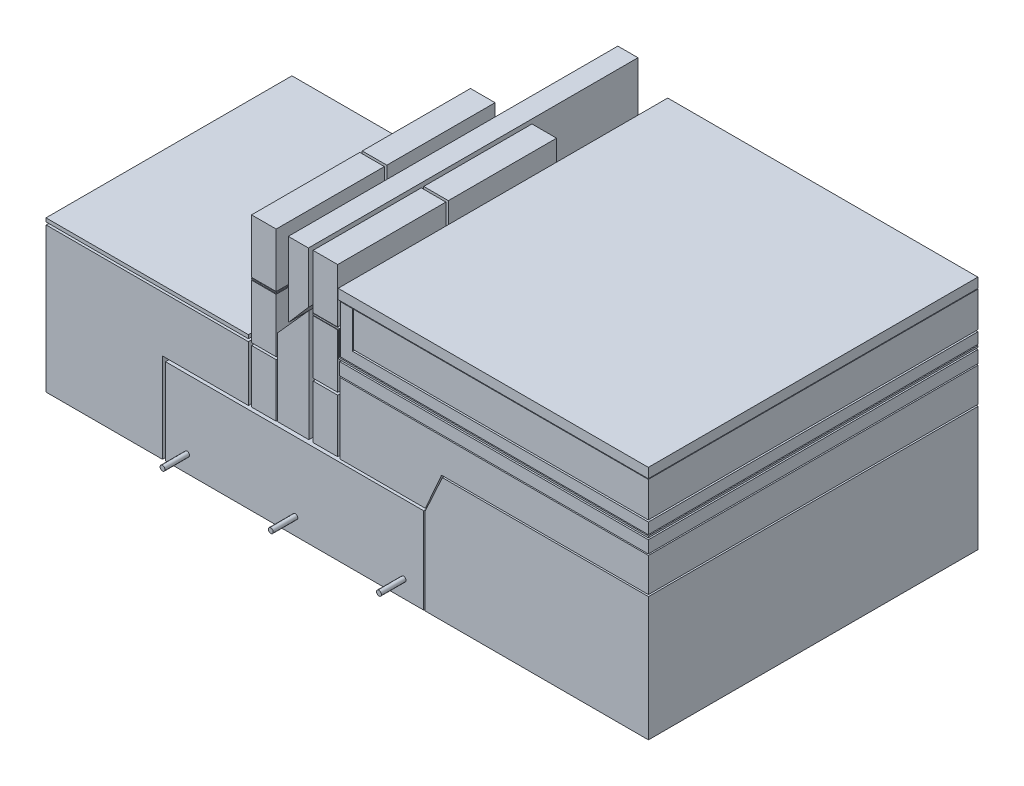
from build123d import *

# Parameters (mm, degrees)
SKETCH1_W        = 1050
SKETCH1_H        = 350
EXTRUDE1_DEPTH   = 1500
SKETCH2_W        = 100
SKETCH2_H        = 216.893893569
EXTRUDE2_DEPTH   = 440
EXTRUDE2_2_DEPTH = 440
SKETCH3_W        = 440
SKETCH3_H        = 220
EXTRUDE3_DEPTH   = 100
EXTRUDE3_2_DEPTH = 100
SKETCH4_W        = 440
SKETCH4_H        = 220
EXTRUDE4_DEPTH   = 100
EXTRUDE4_2_DEPTH = 100
SKETCH6_W        = 215
SKETCH6_H        = 220
EXTRUDE6_DEPTH   = 100
SKETCH6_W_2      = 445.705034037
EXTRUDE6_2_DEPTH = 100
SKETCH6_W_3      = 440
EXTRUDE6_3_DEPTH = 100
SKETCH7_W        = 215
SKETCH7_H        = 220
EXTRUDE7_DEPTH   = 100
SKETCH7_W_2      = 445.705034037
EXTRUDE7_2_DEPTH = 100
SKETCH7_W_3      = 440
EXTRUDE7_3_DEPTH = 100
SKETCH8_W        = 440
SKETCH8_H        = 220
EXTRUDE8_DEPTH   = 100
EXTRUDE8_2_DEPTH = 100
SKETCH9_W        = 440
SKETCH9_H        = 220
EXTRUDE9_DEPTH   = 100
EXTRUDE9_2_DEPTH = 100
SKETCH10_R       = 10
EXTRUDE10_DEPTH  = 100
EXTRUDE11_DEPTH  = 1340
EXTRUDE12_DEPTH  = 1340
EXTRUDE13_DEPTH  = 1340
SKETCH15_W       = 1254.62123021
SKETCH15_H       = 49.983581464
EXTRUDE23_DEPTH  = 1340
SKETCH19_W       = 100.016924429
SKETCH19_H       = 4.415976872
EXTRUDE19_DEPTH  = 1120.705034
EXTRUDE20_DEPTH  = 1000
SKETCH21_W       = 823.020838783
SKETCH21_H       = 14.433926192
EXTRUDE21_DEPTH  = 1000
EXTRUDE22_DEPTH  = 1340
EXTRUDE24_DEPTH  = 1340
EXTRUDE25_DEPTH  = 1340
SKETCH25_W       = 1199.126531933
SKETCH25_H       = 142.62133479
EXTRUDE26_DEPTH  = 1340
SKETCH26_W       = 1261.111632154
SKETCH26_H       = 40
EXTRUDE28_DEPTH  = 1340


with BuildPart() as part:
    # Sketch1 → Extrude1 (new body)
    with BuildSketch(Plane.XY):
        with Locations((-525, 175)):
            Rectangle(SKETCH1_W, SKETCH1_H)
    extrude(amount=-EXTRUDE1_DEPTH)

    # Sketch10 → Extrude10 (add)
    with BuildSketch(Plane.XY):
        with Locations((-962.14462561, 68.901890749)):
            Circle(SKETCH10_R)
        with Locations((-522.14462561, 68.901890749)):
            Circle(SKETCH10_R)
        with Locations((-82.14462561, 68.901890749)):
            Circle(SKETCH10_R)
    extrude(amount=EXTRUDE10_DEPTH)


with BuildPart() as body_2:
    # Sketch2 → Extrude2 (new body)
    with BuildSketch(Plane.XY):
        with Locations((-650, 473.646207299)):
            Rectangle(SKETCH2_W, SKETCH2_H)
    extrude(amount=-EXTRUDE2_DEPTH)


with BuildPart() as body_3:
    # Sketch2 → Extrude2 2 (new body)
    with BuildSketch(Plane.XY):
        with Locations((-400, 473.646207299)):
            Rectangle(SKETCH2_W, SKETCH2_H)
    extrude(amount=-EXTRUDE2_2_DEPTH)


with BuildPart() as body_4:
    # Sketch3 → Extrude3 (new body)
    with BuildSketch(Plane.ZY.offset(700)):
        with Locations((-670, 472.093154083)):
            Rectangle(SKETCH3_W, SKETCH3_H)
    extrude(amount=-EXTRUDE3_DEPTH)


with BuildPart() as body_5:
    # Sketch3 → Extrude3 2 (new body)
    with BuildSketch(Plane.ZY.offset(700)):
        with Locations((-1120, 472.093154083)):
            Rectangle(SKETCH3_W, SKETCH3_H)
    extrude(amount=-EXTRUDE3_2_DEPTH)


with BuildPart() as body_6:
    # Sketch4 → Extrude4 (new body)
    with BuildSketch(Plane(origin=(-350, 0, 0), x_dir=(0, 0, -1), z_dir=(1, 0, 0))):
        with Locations((670, 472.093154083)):
            Rectangle(SKETCH4_W, SKETCH4_H)
    extrude(amount=-EXTRUDE4_DEPTH)


with BuildPart() as body_7:
    # Sketch4 → Extrude4 2 (new body)
    with BuildSketch(Plane(origin=(-350, 0, 0), x_dir=(0, 0, -1), z_dir=(1, 0, 0))):
        with Locations((1120, 472.093154083)):
            Rectangle(SKETCH4_W, SKETCH4_H)
    extrude(amount=-EXTRUDE4_2_DEPTH)


with BuildPart() as body_8:
    # Sketch6 → Extrude6 (new body)
    with BuildSketch(Plane.ZY.offset(700)):
        with Locations((-107.5, 702.093154083)):
            Rectangle(SKETCH6_W, SKETCH6_H)
    extrude(amount=-EXTRUDE6_DEPTH)


with BuildPart() as body_9:
    # Sketch6 → Extrude6 2 (new body)
    with BuildSketch(Plane.ZY.offset(700)):
        with Locations((-447.852517019, 702.093154083)):
            Rectangle(SKETCH6_W_2, SKETCH6_H)
    extrude(amount=-EXTRUDE6_2_DEPTH)


with BuildPart() as body_10:
    # Sketch6 → Extrude6 3 (new body)
    with BuildSketch(Plane.ZY.offset(700)):
        with Locations((-900.705034037, 702.093154083)):
            Rectangle(SKETCH6_W_3, SKETCH6_H)
    extrude(amount=-EXTRUDE6_3_DEPTH)


with BuildPart() as body_11:
    # Sketch7 → Extrude7 (new body)
    with BuildSketch(Plane(origin=(-350, 0, 0), x_dir=(0, 0, -1), z_dir=(1, 0, 0))):
        with Locations((107.5, 702.093154083)):
            Rectangle(SKETCH7_W, SKETCH7_H)
    extrude(amount=-EXTRUDE7_DEPTH)


with BuildPart() as body_12:
    # Sketch7 → Extrude7 2 (new body)
    with BuildSketch(Plane(origin=(-350, 0, 0), x_dir=(0, 0, -1), z_dir=(1, 0, 0))):
        with Locations((447.852517019, 702.093154083)):
            Rectangle(SKETCH7_W_2, SKETCH7_H)
    extrude(amount=-EXTRUDE7_2_DEPTH)


with BuildPart() as body_13:
    # Sketch7 → Extrude7 3 (new body)
    with BuildSketch(Plane(origin=(-350, 0, 0), x_dir=(0, 0, -1), z_dir=(1, 0, 0))):
        with Locations((900.705034037, 702.093154083)):
            Rectangle(SKETCH7_W_3, SKETCH7_H)
    extrude(amount=-EXTRUDE7_3_DEPTH)


with BuildPart() as body_14:
    # Sketch8 → Extrude8 (new body)
    with BuildSketch(Plane.ZY.offset(700)):
        with Locations((-220, 932.093154083)):
            Rectangle(SKETCH8_W, SKETCH8_H)
    extrude(amount=-EXTRUDE8_DEPTH)


with BuildPart() as body_15:
    # Sketch8 → Extrude8 2 (new body)
    with BuildSketch(Plane.ZY.offset(700)):
        with Locations((-670, 932.093154083)):
            Rectangle(SKETCH8_W, SKETCH8_H)
    extrude(amount=-EXTRUDE8_2_DEPTH)


with BuildPart() as body_16:
    # Sketch9 → Extrude9 (new body)
    with BuildSketch(Plane(origin=(-350, 0, 0), x_dir=(0, 0, -1), z_dir=(1, 0, 0))):
        with Locations((220, 932.093154083)):
            Rectangle(SKETCH9_W, SKETCH9_H)
    extrude(amount=-EXTRUDE9_DEPTH)


with BuildPart() as body_17:
    # Sketch9 → Extrude9 2 (new body)
    with BuildSketch(Plane(origin=(-350, 0, 0), x_dir=(0, 0, -1), z_dir=(1, 0, 0))):
        with Locations((670, 932.093154083)):
            Rectangle(SKETCH9_W, SKETCH9_H)
    extrude(amount=-EXTRUDE9_2_DEPTH)


with BuildPart() as body_18:
    # Sketch11 → Extrude11 (new body)
    with BuildSketch(Plane.XY):
        Polygon((-467.142623081, 366.760238591), (-467.142623081, 821.047790695), (-593.71305263, 680.021419663), (-593.71305263, 366.760238591), align=None)
    extrude(amount=-EXTRUDE11_DEPTH)


with BuildPart() as body_19:
    # Sketch12 → Extrude12 (new body)
    with BuildSketch(Plane.XY):
        Polygon((-468.887831959, 831.987849689), (-468.887831959, 1040.989689962), (-550.716667875, 1040.989689962), (-550.716667875, 737.60580318), align=None)
    extrude(amount=-EXTRUDE12_DEPTH)


with BuildPart() as body_20:
    # Sketch13 → Extrude13 (new body)
    with BuildSketch(Plane.XY):
        Polygon((6.53994331, 361.986236304), (72.372848708, 511.620468575), (913.666899137, 511.620468575), (913.666899137, 649.537526022), (-341.378323634, 649.537526022), (-341.378323634, 361.986236304), align=None)
    extrude(amount=-EXTRUDE13_DEPTH)


with BuildPart() as body_21:
    # Sketch15 → Extrude23 (new body)
    with BuildSketch(Plane.XY):
        with Locations((285.822318706, 679.529316754)):
            Rectangle(SKETCH15_W, SKETCH15_H)
    extrude(amount=-EXTRUDE23_DEPTH)


with BuildPart() as body_22:
    # Sketch19 → Extrude19 (new body)
    with BuildSketch(Plane.XY):
        with Locations((-650.08879901, 817.553634615)):
            Rectangle(SKETCH19_W, SKETCH19_H)
    extrude(amount=-EXTRUDE19_DEPTH)


with BuildPart() as body_23:
    # Sketch20 → Extrude20 (new body)
    with BuildSketch(Plane.XY):
        Polygon((-712.863313009, 364.153507118), (-712.863313009, 588.902160457), (-1535.112662731, 588.902160457), (-1535.112662731, 0), (-1062.502562923, 0), (-1062.502562923, 364.153507118), align=None)
    extrude(amount=-EXTRUDE20_DEPTH)


with BuildPart() as body_24:
    # Sketch21 → Extrude21 (new body)
    with BuildSketch(Plane.XY):
        with Locations((-1124.373732401, 606.511632193)):
            Rectangle(SKETCH21_W, SKETCH21_H)
    extrude(amount=-EXTRUDE21_DEPTH)


with BuildPart() as body_25:
    # Sketch22 → Extrude22 (new body)
    with BuildSketch(Plane.XY):
        Polygon((5.344296461, 0), (5.344296461, 350.340899577), (75.947102693, 504.637515893), (913.666899137, 504.637515893), (913.666899137, 0), align=None)
    extrude(amount=-EXTRUDE22_DEPTH)


with BuildPart() as body_26:
    # Sketch23 → Extrude24 (new body)
    with BuildSketch(Plane.XY):
        Polygon((-450.324479407, 820.465755421), (-342.588065822, 820.465755421), (-342.588065822, 718.31944158), (913.132933811, 718.31944158), (913.132933811, 711.148693722), (-346.63517994, 711.148693722), (-346.63517994, 814.02634415), (-450.324479407, 814.02634415), align=None)
    extrude(amount=-EXTRUDE24_DEPTH)


with BuildPart() as body_27:
    # Sketch24 → Extrude25 (new body)
    with BuildSketch(Plane.XY):
        Polygon((-289.031475524, 766.948038505), (-289.031475524, 916.948038505), (-339.171836859, 916.948038505), (-339.171836859, 722.491983655), (913.132933811, 722.491983655), (913.132933811, 766.948038505), align=None)
    extrude(amount=-EXTRUDE25_DEPTH)


with BuildPart() as body_28:
    # Sketch25 → Extrude26 (new body)
    with BuildSketch(Plane.XY):
        with Locations((313.569667845, 845.63737111)):
            Rectangle(SKETCH25_W, SKETCH25_H)
    extrude(amount=-EXTRUDE26_DEPTH)


with BuildPart() as body_29:
    # Sketch26 → Extrude28 (new body)
    with BuildSketch(Plane(origin=(0, 0, -1340), x_dir=(-1, 0, 0), z_dir=(0, 0, -1))):
        with Locations((-282.577117734, 939.487401578)):
            Rectangle(SKETCH26_W, SKETCH26_H)
    extrude(amount=-EXTRUDE28_DEPTH)


solid = Compound([part.part, body_2.part, body_3.part, body_4.part, body_5.part, body_6.part, body_7.part, body_8.part, body_9.part, body_10.part, body_11.part, body_12.part, body_13.part, body_14.part, body_15.part, body_16.part, body_17.part, body_18.part, body_19.part, body_20.part, body_21.part, body_22.part, body_23.part, body_24.part, body_25.part, body_26.part, body_27.part, body_28.part, body_29.part])
